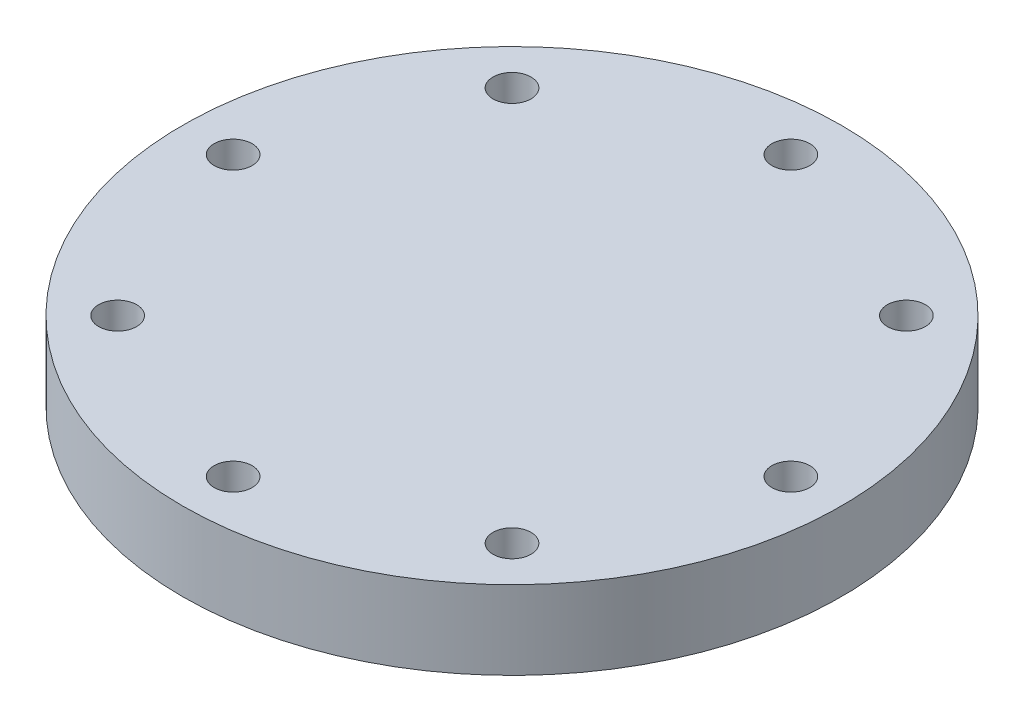
from build123d import *

# Parameters (mm, degrees)
SKETCH1_R           = 26
BOSS_EXTRUDE1_DEPTH = 6.2
SKETCH4_R           = 1.5
CUT_EXTRUDE1_DEPTH  = 13
SKETCH5_R           = 1.5
CUT_EXTRUDE2_DEPTH  = 10
CUT_EXTRUDE3_DEPTH  = 1


with BuildPart() as part:
    # Sketch1 → Boss-Extrude1 (new body)
    with BuildSketch(Plane(origin=(0, 0, 0), x_dir=(1, 0, 0), z_dir=(0, 1, 0))):
        Circle(SKETCH1_R)
    extrude(amount=BOSS_EXTRUDE1_DEPTH)

    # Sketch4 → Cut-Extrude1 (cut)
    with BuildSketch(Plane.XZ):
        with Locations((22, 0)):
            Circle(SKETCH4_R)
    extrude(amount=-CUT_EXTRUDE1_DEPTH, mode=Mode.SUBTRACT)

    # Sketch5 → Cut-Extrude2 (cut)
    with BuildSketch(Plane.XZ):
        with Locations((-22, 0)):
            Circle(SKETCH5_R)
        with Locations((0, 22)):
            Circle(SKETCH5_R)
        with Locations((0, -22)):
            Circle(SKETCH5_R)
        with Locations((-15.556349186, 15.556349186)):
            Circle(SKETCH5_R)
        with Locations((15.556349186, 15.556349186)):
            Circle(SKETCH5_R)
        with Locations((15.556349186, -15.556349186)):
            Circle(SKETCH5_R)
        with Locations((-15.556349186, -15.556349186)):
            Circle(SKETCH5_R)
    extrude(amount=-CUT_EXTRUDE2_DEPTH, mode=Mode.SUBTRACT)

    # Sketch6 → Cut-Extrude3 (cut)
    with BuildSketch(Plane(origin=(0, 0, 0), x_dir=(-1, 0, 0), z_dir=(0, -1, 0))):
        with BuildLine():
            Line((-7.133469585, -15.941578498), (-7.361163896, -15.783210108))
            Line((-7.361163896, -15.783210108), (-6.478371428, -14.492730341))
            add(Edge.make_bspline(
                [(-6.478371428, -14.492730341), (-6.534696595, -14.499618334), (-6.64560399, -14.513181177), (-6.757306933, -14.515672785), (-6.812280683, -14.516899011)],
                knots=[0, 0, 0, 0, 0.000170115, 0.000334967, 0.000334967, 0.000334967, 0.000334967], degree=3))
            add(Edge.make_bspline(
                [(-6.812280683, -14.516899011), (-6.845610969, -14.51604532), (-6.911035406, -14.5143696), (-7.007221263, -14.501087388), (-7.099646021, -14.4806312), (-7.188064651, -14.450106973), (-7.272809488, -14.412171883), (-7.353695528, -14.365130163), (-7.430613885, -14.309788742), (-7.502738465, -14.246440242), (-7.568335542, -14.176882295), (-7.626776676, -14.103262533), (-7.675346132, -14.02472576), (-7.715692748, -13.94287406), (-7.746291089, -13.856530978), (-7.768572819, -13.766679022), (-7.782290955, -13.672688461), (-7.783922991, -13.608712092), (-7.784751636, -13.576228939)],
                knots=[0, 0, 0, 0, 9.9954e-05, 0.000196201, 0.000290782, 0.000383503, 0.000476303, 0.000568919, 0.000663705, 0.000760153, 0.000856434, 0.000950205, 0.001041624, 0.001132931, 0.001223461, 0.001315861, 0.001410305, 0.001507717, 0.001507717, 0.001507717, 0.001507717], degree=3))
            add(Edge.make_bspline(
                [(-7.784751636, -13.576228939), (-7.783178256, -13.531807375), (-7.78009003, -13.444616857), (-7.755235661, -13.317223367), (-7.714359496, -13.196767002), (-7.657365183, -13.083564469), (-7.585578686, -12.979244184), (-7.499301608, -12.885256374), (-7.399058726, -12.802937828), (-7.287133608, -12.732176987), (-7.166163368, -12.675267382), (-7.039463942, -12.633321731), (-6.908006134, -12.608648581), (-6.818954033, -12.605395693), (-6.774119625, -12.603757985)],
                knots=[0, 0, 0, 0, 0.000133185, 0.000261414, 0.000387724, 0.00051373, 0.000640399, 0.00076644, 0.000895188, 0.001028407, 0.001162697, 0.001295241, 0.001427846, 0.0015623, 0.0015623, 0.0015623, 0.0015623], degree=3))
            add(Edge.make_bspline(
                [(-6.774119625, -12.603757985), (-6.730133702, -12.605418204), (-6.643221663, -12.608698641), (-6.515415207, -12.632723385), (-6.393004427, -12.673215224), (-6.276667904, -12.729171935), (-6.168954294, -12.799313044), (-6.072093379, -12.882892219), (-5.988295569, -12.979961519), (-5.917698191, -13.088173221), (-5.861028941, -13.204438982), (-5.820141941, -13.325800112), (-5.794972683, -13.451383809), (-5.791801015, -13.536468796), (-5.790200354, -13.579409027)],
                knots=[0, 0, 0, 0, 0.000131915, 0.000260652, 0.000388569, 0.000517718, 0.000646848, 0.000773094, 0.000900237, 0.001030248, 0.001159674, 0.001287189, 0.001413545, 0.001542287, 0.001542287, 0.001542287, 0.001542287], degree=3))
            add(Edge.make_bspline(
                [(-5.790200354, -13.579409027), (-5.79126934, -13.612740873), (-5.793437509, -13.680346185), (-5.80861973, -13.783062281), (-5.834400898, -13.887793039), (-5.863657796, -13.976440487), (-5.89189912, -14.049654581), (-5.918479432, -14.107486371), (-5.9479726, -14.168356803), (-5.982370337, -14.231627602), (-6.019347564, -14.29810533), (-6.061129907, -14.367123223), (-6.106764248, -14.438773895), (-6.139266922, -14.48707661), (-6.155910491, -14.51181087)],
                knots=[0, 0, 0, 0, 9.9984e-05, 0.000202793, 0.000310776, 0.000423207, 0.000482616, 0.000546097, 0.000614079, 0.0006855, 0.000762103, 0.000842274, 0.000927493, 0.001016928, 0.001016928, 0.001016928, 0.001016928], degree=3))
            Line((-6.155910491, -14.51181087), (-7.133469585, -15.941578498))
        make_face()
        with BuildLine():
            add(Edge.make_bspline(
                [(-6.75949122, -14.191257985), (-6.734241793, -14.190568208), (-6.685089742, -14.189225448), (-6.613083192, -14.181052778), (-6.545116236, -14.166562091), (-6.481007317, -14.145770638), (-6.420113628, -14.120682088), (-6.363402387, -14.088739786), (-6.310826133, -14.050624696), (-6.262032799, -14.007798468), (-6.218704028, -13.960218295), (-6.180111422, -13.910418777), (-6.147308621, -13.85818131), (-6.121397648, -13.802851707), (-6.100093783, -13.745776811), (-6.08538173, -13.686037503), (-6.077231656, -13.623945025), (-6.075842299, -13.5817641), (-6.075136252, -13.560328498)],
                knots=[0, 0, 0, 0, 7.5753e-05, 0.000147465, 0.000217073, 0.000283852, 0.000349411, 0.000414338, 0.000478589, 0.000543925, 0.000608743, 0.000671332, 0.000732749, 0.000793345, 0.000854313, 0.000915245, 0.00097749, 0.001041807, 0.001041807, 0.001041807, 0.001041807], degree=3))
            add(Edge.make_bspline(
                [(-6.075136252, -13.560328498), (-6.075743737, -13.538883944), (-6.076940862, -13.496624821), (-6.086545056, -13.434440415), (-6.103440794, -13.374847242), (-6.126110733, -13.317519052), (-6.155974092, -13.262926858), (-6.191809397, -13.21038526), (-6.234383834, -13.160227401), (-6.283371876, -13.11363293), (-6.336198935, -13.070681622), (-6.392496674, -13.032775681), (-6.451801062, -13.001006453), (-6.513750292, -12.974790959), (-6.578473437, -12.954333277), (-6.645932198, -12.93962181), (-6.716467459, -12.931483147), (-6.764347626, -12.930102571), (-6.788748031, -12.929399011)],
                knots=[0, 0, 0, 0, 6.4316e-05, 0.000126743, 0.000188161, 0.000249812, 0.000311283, 0.000374438, 0.00044032, 0.000508243, 0.00057698, 0.000644365, 0.000711521, 0.0007785, 0.000845884, 0.000914871, 0.00098532, 0.001058531, 0.001058531, 0.001058531, 0.001058531], degree=3))
            add(Edge.make_bspline(
                [(-6.788748031, -12.929399011), (-6.812936227, -12.930103708), (-6.860393269, -12.931486318), (-6.930301471, -12.93960634), (-6.997304101, -12.954432215), (-7.061839714, -12.974781483), (-7.123787103, -13.001008409), (-7.183088694, -13.032777346), (-7.239399603, -13.070672896), (-7.292176014, -13.113666725), (-7.341250557, -13.160010519), (-7.383093001, -13.210604986), (-7.419010318, -13.262899526), (-7.448832642, -13.317526316), (-7.471513497, -13.374845304), (-7.488406312, -13.43444094), (-7.498011291, -13.496624685), (-7.499208308, -13.538883898), (-7.499815739, -13.560328498)],
                knots=[0, 0, 0, 0, 7.2576e-05, 0.000142393, 0.000210758, 0.000278143, 0.000345121, 0.000412278, 0.000479663, 0.0005484, 0.000616323, 0.000681795, 0.00074495, 0.000806421, 0.000868072, 0.00092949, 0.000991917, 0.001056233, 0.001056233, 0.001056233, 0.001056233], degree=3))
            add(Edge.make_bspline(
                [(-7.499815739, -13.560328498), (-7.499266077, -13.581780792), (-7.498182044, -13.624088644), (-7.487724692, -13.686251872), (-7.470236538, -13.745840447), (-7.446814663, -13.803433775), (-7.415970363, -13.858471817), (-7.378120872, -13.910693638), (-7.333756556, -13.960691225), (-7.283470463, -14.007687768), (-7.228435774, -14.050824384), (-7.169655869, -14.088498373), (-7.10814266, -14.120314091), (-7.043679609, -14.145842346), (-6.97674444, -14.166354355), (-6.906735571, -14.181026071), (-6.833884527, -14.189147056), (-6.784526901, -14.190547591), (-6.75949122, -14.191257985)],
                knots=[0, 0, 0, 0, 6.4316e-05, 0.000126844, 0.000188436, 0.000250326, 0.000312966, 0.000377217, 0.000443451, 0.000513196, 0.000583426, 0.000652939, 0.000722346, 0.000790847, 0.000860662, 0.000932137, 0.001005113, 0.00108023, 0.00108023, 0.00108023, 0.00108023], degree=3))
        make_face(mode=Mode.SUBTRACT)
        Polygon((-5.179623431, -12.685168241), (-3.225777277, -12.685168241), (-4.894687534, -15.941578498), (-5.140826356, -15.806106743), (-3.70787864, -13.010809267), (-5.179623431, -13.010809267), align=None)
    extrude(amount=-CUT_EXTRUDE3_DEPTH, mode=Mode.SUBTRACT)


solid = part.part
